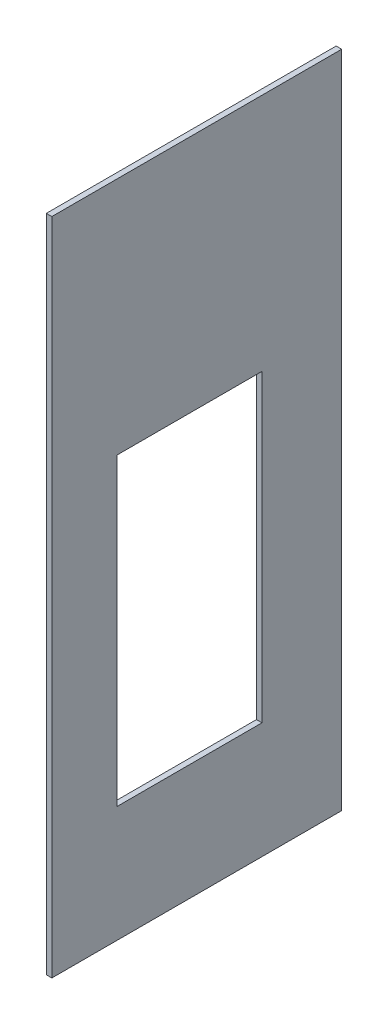
from build123d import *

# Parameters (mm, degrees)
SKETCH1_W           = 63.5
SKETCH1_H           = 144.4625
BOSS_EXTRUDE1_DEPTH = 1.21412
SKETCH3_W           = 31.75
SKETCH3_H           = 66.675
CUT_EXTRUDE1_DEPTH  = 2.21412


with BuildPart() as part:
    # Sketch1 → Boss-Extrude1 (new body)
    with BuildSketch(Plane(origin=(0, 0, 0), x_dir=(0, 0, -1), z_dir=(1, 0, 0))):
        Rectangle(SKETCH1_W, SKETCH1_H)
    extrude(amount=BOSS_EXTRUDE1_DEPTH)

    # Sketch3 → Cut-Extrude1 (cut, through all)
    with BuildSketch(Plane(origin=(1.21412, 0, 0), x_dir=(0, 0, -1), z_dir=(1, 0, 0))):
        with Locations((-1.5875, -13.49375)):
            Rectangle(SKETCH3_W, SKETCH3_H)
    extrude(amount=-CUT_EXTRUDE1_DEPTH, mode=Mode.SUBTRACT)


solid = part.part
